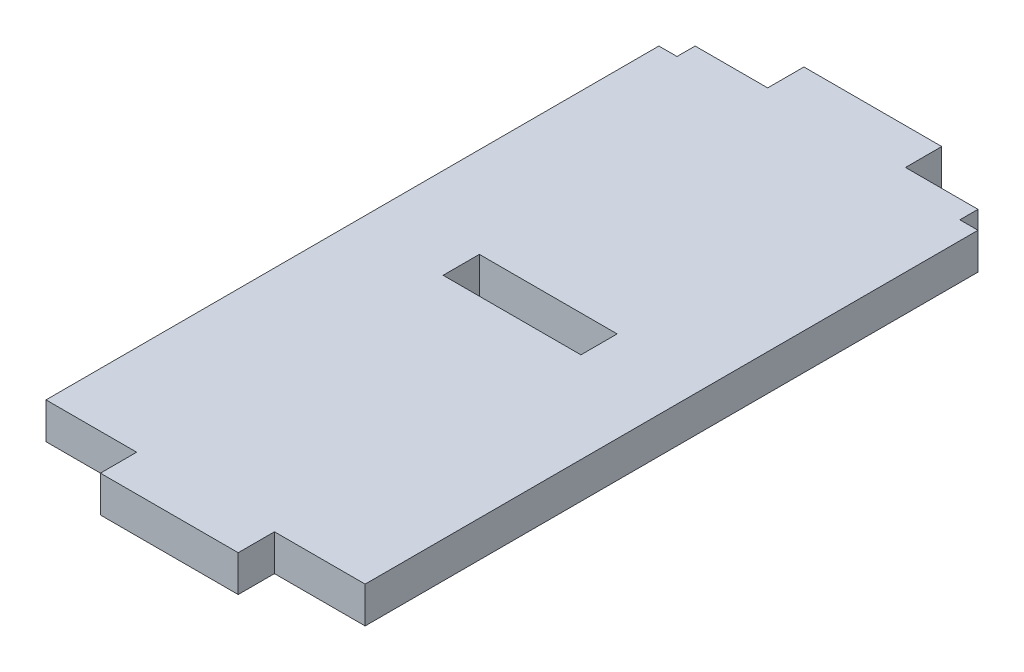
from build123d import *

# Parameters (mm, degrees)
SKETCH_1_W      = 7.6
SKETCH_1_H      = 2
EXTRUDE_1_DEPTH = 2


with BuildPart() as part:
    # 草图1 → 凸台-拉伸1 (new body)
    with BuildSketch(Plane(origin=(0, 0, 0), x_dir=(1, 0, 0), z_dir=(0, 1, 0))):
        Polygon((0, 33.8), (0, 0), (5, 0), (5, -2), (12.6, -2), (12.6, 0), (17.6, 0), (17.6, 33.8), (16.6, 33.8), (16.6, 34.8), (12.6, 34.8), (12.6, 36.8), (5, 36.8), (5, 34.8), (1, 34.8), (1, 33.8), align=None)
        with Locations((8.8, 17.9)):
            Rectangle(SKETCH_1_W, SKETCH_1_H, mode=Mode.SUBTRACT)
    extrude(amount=EXTRUDE_1_DEPTH)


solid = part.part
